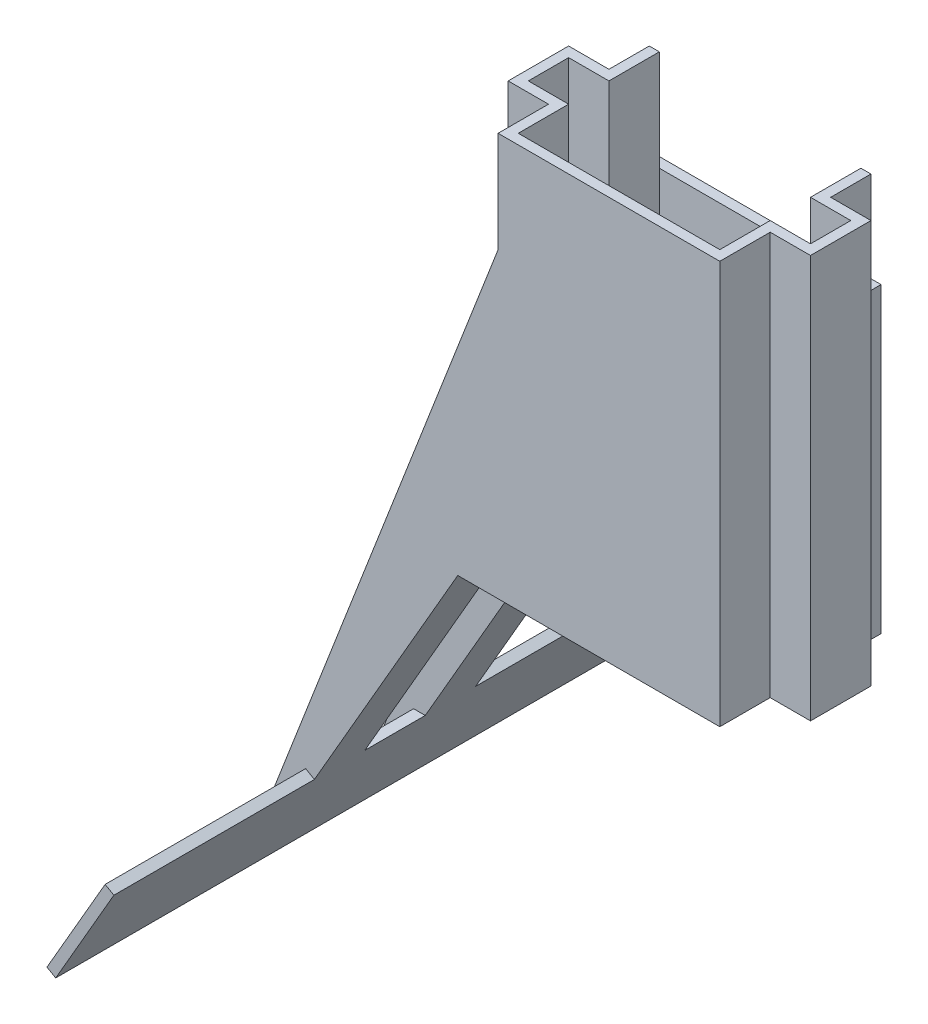
from build123d import *

# Parameters (mm, degrees)
AUFSATZ_LINEAR_AUSTRAGEN1_DEPTH = 20
SKIZZE2_W                       = 11
SKIZZE2_H                       = 5
SCHNITT_LINEAR_AUSTRAGEN1_DEPTH = 0.5
AUFSATZ_LINEAR_AUSTRAGEN2_DEPTH = 8
SKIZZE4_W                       = 1.5
SKIZZE4_H                       = 2
SCHNITT_LINEAR_AUSTRAGEN2_DEPTH = 8
AUFSATZ_LINEAR_AUSTRAGEN3_DEPTH = 2.5
SKIZZE8_W                       = 3
SKIZZE8_H                       = 12.320508076
SCHNITT_LINEAR_AUSTRAGEN5_DEPTH = 12
SKIZZE9_W                       = 9.95
SKIZZE9_H                       = 5.773502692
SKIZZE9_W_2                     = 10
AUFSATZ_LINEAR_AUSTRAGEN5_DEPTH = 0.5
AUFSATZ_LINEAR_AUSTRAGEN6_DEPTH = 2.5


with BuildPart() as part:
    # Skizze1 → Aufsatz-Linear austragen1 (new body)
    with BuildSketch(Plane(origin=(0, 0, 0), x_dir=(1, 0, 0), z_dir=(0, 1, 0))):
        Polygon((1.5, 2.5), (1.5, 5), (12.5, 5), (12.5, 2.5), (14.5, 2.5), (14.5, -0.5), (12.5, -0.5), (12.5, -3), (1.5, -3), (1.5, -0.5), (-0.5, -0.5), (-0.5, 2.5), align=None)
        Polygon((2, 2), (2, 4.5), (12, 4.5), (12, 2), (14, 2), (14, 0), (12, 0), (12, -2.5), (2, -2.5), (2, 0), (0, 0), (0, 2), align=None, mode=Mode.SUBTRACT)
    extrude(amount=AUFSATZ_LINEAR_AUSTRAGEN1_DEPTH)

    # Skizze2 → Schnitt-Linear austragen1 (cut)
    with BuildSketch(Plane(origin=(0, 0, -5), x_dir=(-1, 0, 0), z_dir=(0, 0, -1))):
        with Locations((-7, 17.5)):
            Rectangle(SKIZZE2_W, SKIZZE2_H)
    extrude(amount=-SCHNITT_LINEAR_AUSTRAGEN1_DEPTH, mode=Mode.SUBTRACT)

    # Skizze3 → Aufsatz-Linear austragen2 (add)
    with BuildSketch(Plane(origin=(0, 0, -5), x_dir=(-1, 0, 0), z_dir=(0, 0, -1))):
        Polygon((-1.5, 0), (0.5, 0), (10.5, -17.320508076), (10.933012702, -17.070508076), (0.788675135, 0.5), (-1.5, 0.5), align=None)
    extrude(amount=-AUFSATZ_LINEAR_AUSTRAGEN2_DEPTH)

    # Skizze4 → Schnitt-Linear austragen2 (cut)
    with BuildSketch(Plane(origin=(0, 0.5, 0), x_dir=(1, 0, 0), z_dir=(0, 1, 0))):
        with Locations((0.75, 1)):
            Rectangle(SKIZZE4_W, SKIZZE4_H)
    extrude(amount=-SCHNITT_LINEAR_AUSTRAGEN2_DEPTH, mode=Mode.SUBTRACT)

    # Skizze6 → Aufsatz-Linear austragen3 (add)
    with BuildSketch(Plane(origin=(0, 0, -5), x_dir=(-1, 0, 0), z_dir=(0, 0, -1))):
        Polygon((-1.5, 15), (10.933012702, -17.070508076), (0.788675135, 0.5), (-1.5, 0.5), align=None)
    extrude(amount=-AUFSATZ_LINEAR_AUSTRAGEN3_DEPTH)

    # Skizze8 → Schnitt-Linear austragen5 (cut)
    with BuildSketch(Plane(origin=(0, 0, 0), x_dir=(0, 0, -1), z_dir=(1, 0, 0))):
        with Locations((1, -6.160254038)):
            Rectangle(SKIZZE8_W, SKIZZE8_H)
    extrude(amount=-SCHNITT_LINEAR_AUSTRAGEN5_DEPTH, mode=Mode.SUBTRACT)

    # Skizze9 → Aufsatz-Linear austragen5 (add)
    with BuildSketch(Plane(origin=(-0.375, 0.216506351, 0), x_dir=(0, 0, -1), z_dir=(0.866025404, -0.5, 0))):
        with Locations((-7.975, -17.363248654)):
            Rectangle(SKIZZE9_W, SKIZZE9_H)
        with Locations((10, -17.363248654)):
            Rectangle(SKIZZE9_W_2, SKIZZE9_H)
    extrude(amount=-AUFSATZ_LINEAR_AUSTRAGEN5_DEPTH)

    # Skizze11 → Aufsatz-Linear austragen6 (add)
    with BuildSketch(Plane.XY.offset(0.5)):
        Polygon((1.5, 0.5), (-0.788675135, 0.5), (-10.933012702, -17.070508076), (1.5, 15), align=None)
    extrude(amount=AUFSATZ_LINEAR_AUSTRAGEN6_DEPTH)


solid = part.part
